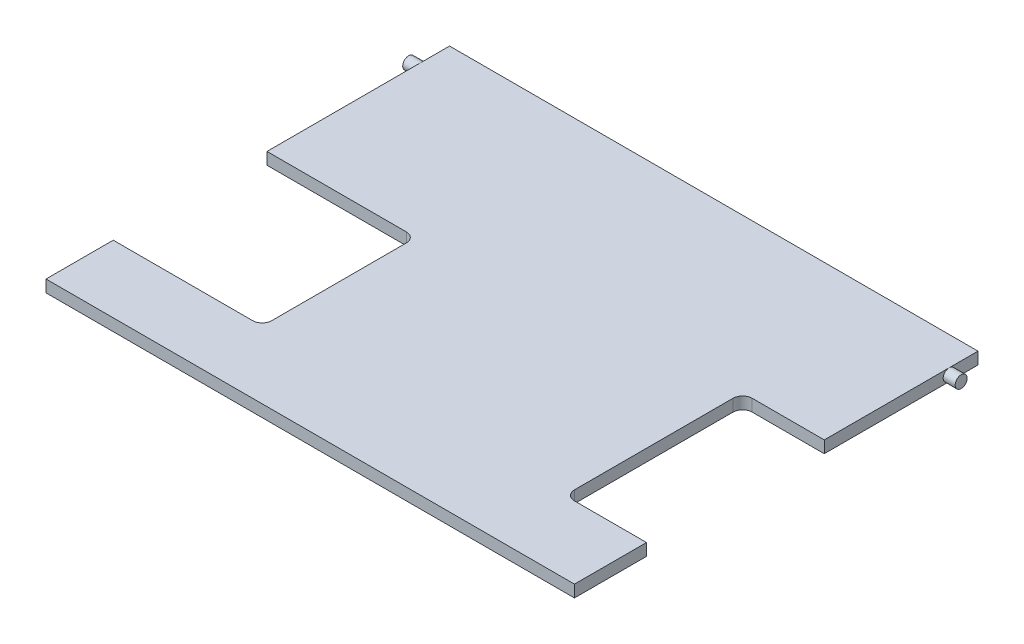
from build123d import *

# Parameters (mm, degrees)
CROQUIS1_W              = 110
CROQUIS1_H              = 84
SALIENTE_EXTRUIR1_DEPTH = 2.5
CROQUIS2_R              = 1.25
SALIENTE_EXTRUIR2_DEPTH = 2.5
CROQUIS3_R              = 1.25
SALIENTE_EXTRUIR3_DEPTH = 2.5
CORTAR_EXTRUIR1_DEPTH   = 10


with BuildPart() as part:
    # Croquis1 → Saliente-Extruir1 (new body)
    with BuildSketch(Plane(origin=(0, 0, 0), x_dir=(1, 0, 0), z_dir=(0, 1, 0))):
        with Locations((-55, 42)):
            Rectangle(CROQUIS1_W, CROQUIS1_H)
    extrude(amount=SALIENTE_EXTRUIR1_DEPTH)

    # Croquis2 → Saliente-Extruir2 (add)
    with BuildSketch(Plane(origin=(0, 0, 0), x_dir=(0, 0, -1), z_dir=(1, 0, 0))):
        with Locations((78, 1.25)):
            Circle(CROQUIS2_R)
    extrude(amount=SALIENTE_EXTRUIR2_DEPTH)

    # Croquis3 → Saliente-Extruir3 (add)
    with BuildSketch(Plane.ZY.offset(110)):
        with Locations((-78, 1.25)):
            Circle(CROQUIS3_R)
    extrude(amount=SALIENTE_EXTRUIR3_DEPTH)

    # Croquis4 → Cortar-Extruir1 (cut)
    with BuildSketch(Plane(origin=(0, 2.5, 0), x_dir=(1, 0, 0), z_dir=(0, 1, 0))):
        with BuildLine():
            Line((-81, 46), (-110, 46))
            Line((-110, 46), (-110, 14))
            Line((-110, 14), (-81, 14))
            ThreePointArc((-81, 14), (-79.585786438, 14.585786438), (-79, 16))
            Line((-79, 16), (-79, 44))
            ThreePointArc((-79, 44), (-79.585786438, 45.414213562), (-81, 46))
        make_face()
        with BuildLine():
            Line((-17, 17), (-17, 50))
            ThreePointArc((-17, 50), (-16.414213562, 51.414213562), (-15, 52))
            Line((-15, 52), (0, 52))
            Line((0, 52), (0, 15))
            Line((0, 15), (-15, 15))
            ThreePointArc((-15, 15), (-16.414213562, 15.585786438), (-17, 17))
        make_face()
    extrude(amount=-CORTAR_EXTRUIR1_DEPTH, mode=Mode.SUBTRACT)


solid = part.part
